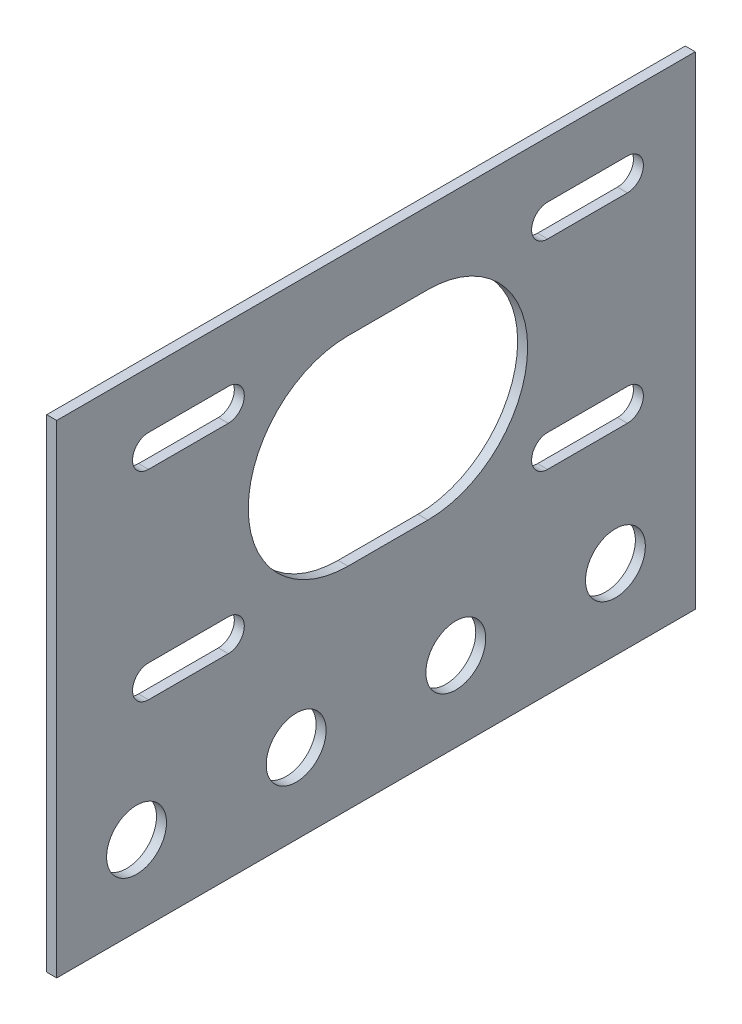
from build123d import *

# Parameters (mm, degrees)
SKETCH1_W           = 101.6
SKETCH1_H           = 76.835
BOSS_EXTRUDE1_DEPTH = 1.5875
SKETCH2_R           = 4.7625
CUT_EXTRUDE1_DEPTH  = 2.5875


with BuildPart() as part:
    # Sketch1 → Boss-Extrude1 (new body)
    with BuildSketch(Plane(origin=(0, 0, 0), x_dir=(0, 0, -1), z_dir=(1, 0, 0))):
        Rectangle(SKETCH1_W, SKETCH1_H)
    extrude(amount=BOSS_EXTRUDE1_DEPTH)

    # Sketch2 → Cut-Extrude1 (cut, through all)
    with BuildSketch(Plane(origin=(1.5875, 0, 0), x_dir=(0, 0, -1), z_dir=(1, 0, 0))):
        with Locations((-38.1, -25.7175)):
            Circle(SKETCH2_R)
        with Locations((-12.7, -25.7175)):
            Circle(SKETCH2_R)
        with Locations((12.7, -25.7175)):
            Circle(SKETCH2_R)
        with Locations((38.1, -25.7175)):
            Circle(SKETCH2_R)
        with BuildLine():
            Line((-36.195, -2.2987), (-23.495, -2.2987))
            ThreePointArc((-23.495, -2.2987), (-20.955, -4.8387), (-23.495, -7.3787))
            Line((-23.495, -7.3787), (-36.195, -7.3787))
            ThreePointArc((-36.195, -7.3787), (-38.735, -4.8387), (-36.195, -2.2987))
        make_face()
        with BuildLine():
            Line((27.305, -2.2987), (40.005, -2.2987))
            ThreePointArc((40.005, -2.2987), (42.545, -4.8387), (40.005, -7.3787))
            Line((40.005, -7.3787), (27.305, -7.3787))
            ThreePointArc((27.305, -7.3787), (24.765, -4.8387), (27.305, -2.2987))
        make_face()
        with BuildLine():
            Line((27.305, 29.4513), (40.005, 29.4513))
            ThreePointArc((40.005, 29.4513), (42.545, 26.9113), (40.005, 24.3713))
            Line((40.005, 24.3713), (27.305, 24.3713))
            ThreePointArc((27.305, 24.3713), (24.765, 26.9113), (27.305, 29.4513))
        make_face()
        with BuildLine():
            Line((-36.195, 29.4513), (-23.495, 29.4513))
            ThreePointArc((-23.495, 29.4513), (-20.955, 26.9113), (-23.495, 24.3713))
            Line((-23.495, 24.3713), (-36.195, 24.3713))
            ThreePointArc((-36.195, 24.3713), (-38.735, 26.9113), (-36.195, 29.4513))
        make_face()
        with BuildLine():
            Line((-4.445, 26.9113), (8.255, 26.9113))
            ThreePointArc((8.255, 26.9113), (24.13, 11.0363), (8.255, -4.8387))
            Line((8.255, -4.8387), (-4.445, -4.8387))
            ThreePointArc((-4.445, -4.8387), (-20.32, 11.0363), (-4.445, 26.9113))
        make_face()
    extrude(amount=-CUT_EXTRUDE1_DEPTH, mode=Mode.SUBTRACT)


solid = part.part
